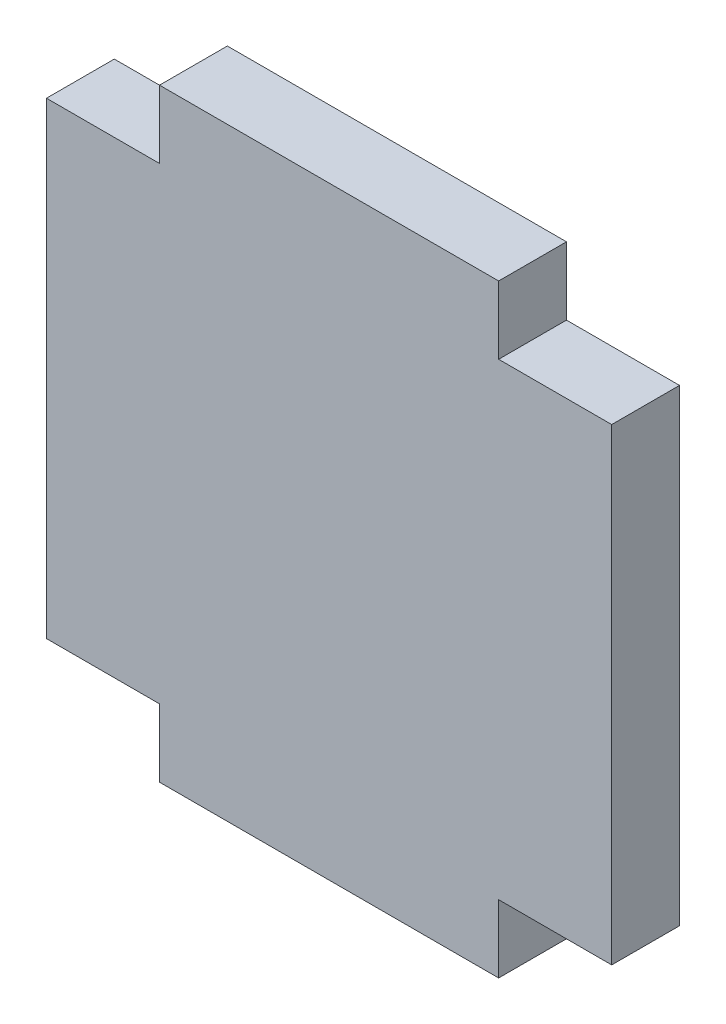
from build123d import *

# Parameters (mm, degrees)
ESBO_O1_W                = 25
ESBO_O1_H                = 20.7
ESBO_O1_W_2              = 15
ESBO_O1_H_2              = 3
RESSALTO_EXTRUS_O1_DEPTH = 3


with BuildPart() as part:
    # Esboço1 → Ressalto-extrusão1 (new body)
    with BuildSketch(Plane.XY):
        Rectangle(ESBO_O1_W, ESBO_O1_H)
        with Locations((0, 11.85)):
            Rectangle(ESBO_O1_W_2, ESBO_O1_H_2)
        with Locations((0, -11.85)):
            Rectangle(ESBO_O1_W_2, ESBO_O1_H_2)
    extrude(amount=RESSALTO_EXTRUS_O1_DEPTH)


solid = part.part
